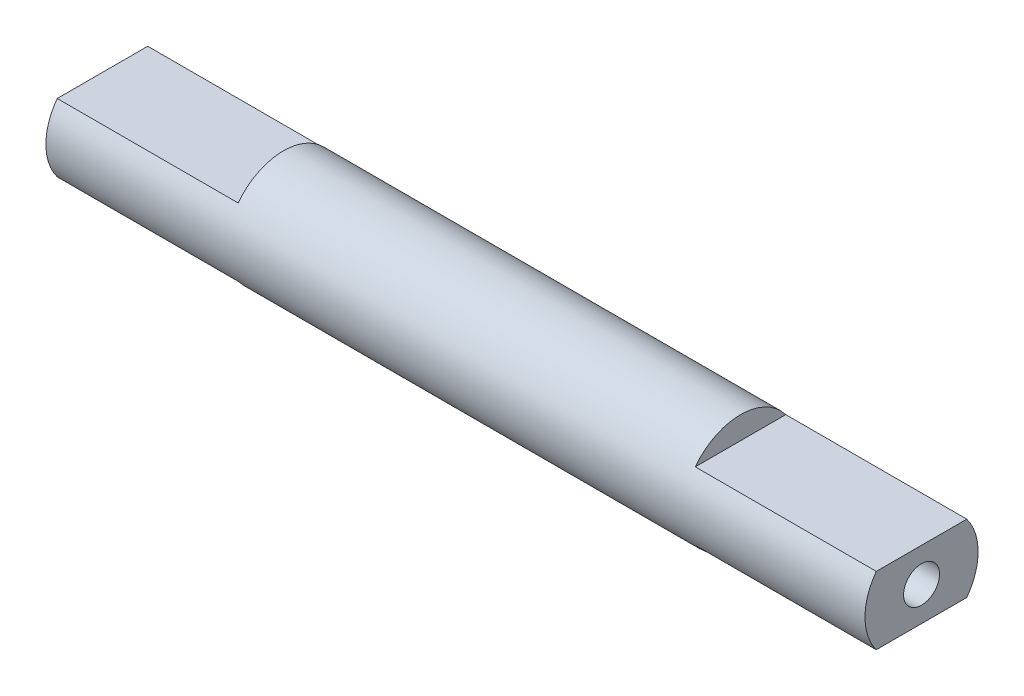
from build123d import *

# Parameters (mm, degrees)
CROQUIS1_R              = 2.5
SALIENTE_EXTRUIR1_DEPTH = 36.2
CROQUIS2_OUTSIDE_W      = 14.376
CROQUIS2_OUTSIDE_H      = 14.376
CROQUIS2_OUTSIDE_W_2    = 5.186631864
CROQUIS2_OUTSIDE_H_2    = 3
CORTAR_EXTRUIR1_DEPTH   = 8
CROQUIS2_3_R            = 0.79375
CORTAR_EXTRUIR2_DEPTH   = 5
CROQUIS3_OUTSIDE_W      = 14.376
CROQUIS3_OUTSIDE_H      = 14.376
CORTAR_EXTRUIR3_DEPTH   = 8
CORTAR_EXTRUIR4_START   = -5
CROQUIS4_R              = 0.79375
CORTAR_EXTRUIR4_DEPTH   = 5


with BuildPart() as part:
    # Croquis1 → Saliente-Extruir1 (new body)
    with BuildSketch(Plane(origin=(0, 0, 0), x_dir=(0, 0, -1), z_dir=(1, 0, 0))):
        Circle(CROQUIS1_R)
    extrude(amount=SALIENTE_EXTRUIR1_DEPTH)

    # Croquis2 outside → Cortar-Extruir1 (cut)
    with BuildSketch(Plane(origin=(36.2, 0, 0), x_dir=(0, 0, -1), z_dir=(1, 0, 0))):
        Rectangle(CROQUIS2_OUTSIDE_W, CROQUIS2_OUTSIDE_H)
        Rectangle(CROQUIS2_OUTSIDE_W_2, CROQUIS2_OUTSIDE_H_2, mode=Mode.SUBTRACT)
    extrude(amount=-CORTAR_EXTRUIR1_DEPTH, mode=Mode.SUBTRACT)

    # Croquis2_3 → Cortar-Extruir2 (cut)
    with BuildSketch(Plane(origin=(36.2, 0, 0), x_dir=(0, 0, -1), z_dir=(1, 0, 0))):
        Circle(CROQUIS2_3_R)
    extrude(amount=-CORTAR_EXTRUIR2_DEPTH, mode=Mode.SUBTRACT)

    # Croquis3 outside → Cortar-Extruir3 (cut)
    with BuildSketch(Plane(origin=(0, 0, 0), x_dir=(0, 0, -1), z_dir=(1, 0, 0))):
        Rectangle(CROQUIS3_OUTSIDE_W, CROQUIS3_OUTSIDE_H)
        with BuildLine():
            Line((2, 1.5), (-2, 1.5))
            ThreePointArc((-2, 1.5), (-2.5, 0), (-2, -1.5))
            Line((-2, -1.5), (2, -1.5))
            ThreePointArc((2, -1.5), (2.5, 0), (2, 1.5))
        make_face(mode=Mode.SUBTRACT)
    extrude(amount=CORTAR_EXTRUIR3_DEPTH, mode=Mode.SUBTRACT)

    # Croquis4 → Cortar-Extruir4 (cut)
    with BuildSketch(Plane.ZY.offset(CORTAR_EXTRUIR4_START)):
        Circle(CROQUIS4_R)
    extrude(amount=CORTAR_EXTRUIR4_DEPTH, mode=Mode.SUBTRACT)


solid = part.part
